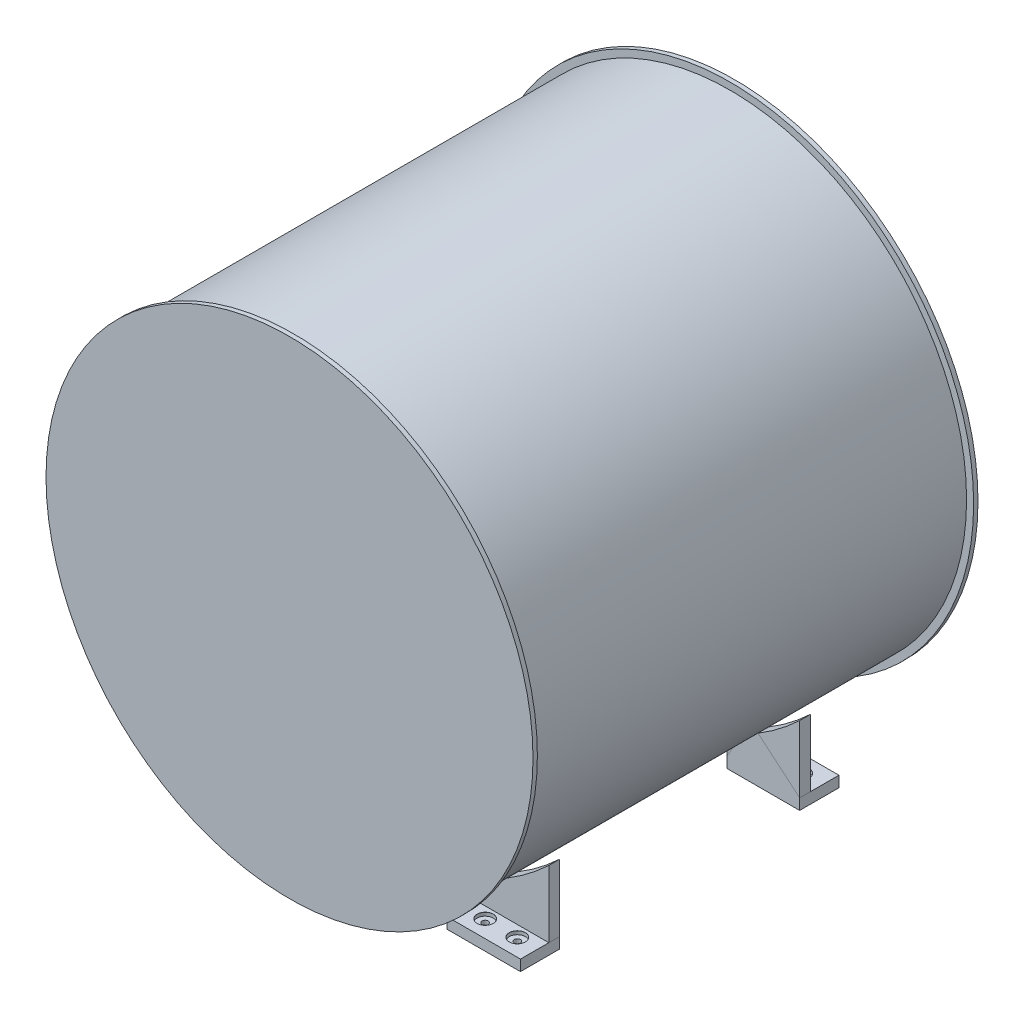
from build123d import *

# Parameters (mm, degrees)
SKETCH1_R                                   = 101.520631511
BOSS_EXTRUDE1_DEPTH                         = 254
SKETCH3_R                                   = 137.670707206
BOSS_EXTRUDE2_DEPTH                         = 254
SKETCH7_R                                   = 141.773218919
BOSS_EXTRUDE3_DEPTH                         = 2.54
SKETCH8_R                                   = 141.773218919
BOSS_EXTRUDE4_DEPTH                         = 2.54
BOSS_EXTRUDE5_DEPTH                         = 6.35
BOSS_EXTRUDE6_DEPTH                         = 6.35
CBORE_FOR_M3_HEX_HEAD_CAP_SCREW1_AT_2_COUNT = 2
CBORE_FOR_M3_HEX_HEAD_CAP_SCREW1_AT_2_PITCH = 18.694620376


with BuildPart() as part:
    # Sketch1 → Boss-Extrude1 (new body)
    with BuildSketch(Plane.XY):
        Circle(SKETCH1_R)
    extrude(amount=BOSS_EXTRUDE1_DEPTH)

    # Sketch3 → Boss-Extrude2 (add)
    with BuildSketch(Plane.XY):
        Circle(SKETCH3_R)
    extrude(amount=BOSS_EXTRUDE2_DEPTH)

    # Sketch7 → Boss-Extrude3 (add)
    with BuildSketch(Plane.XY):
        Circle(SKETCH7_R)
    extrude(amount=-BOSS_EXTRUDE3_DEPTH)

    # Sketch8 → Boss-Extrude4 (add)
    with BuildSketch(Plane.XY.offset(254)):
        Circle(SKETCH8_R)
    extrude(amount=BOSS_EXTRUDE4_DEPTH)


with BuildPart() as body_2:
    # Sketch9 → Boss-Extrude5 (new body)
    with BuildSketch(Plane.XY.offset(50.8)):
        with BuildLine():
            Line((97.638005055, -102.793314818), (97.638005055, -141.773218919))
            Line((97.638005055, -141.773218919), (55.292539207, -141.773218919))
            Line((55.292539207, -141.773218919), (55.292539207, -130.546469545))
            ThreePointArc((55.292539207, -130.546469545), (77.714202315, -118.575496461), (97.638005055, -102.793314818))
        make_face()
    extrude(amount=BOSS_EXTRUDE5_DEPTH)


with BuildPart() as body_3:
    # Mirror2: mirrored copy
    add(body_2.part.mirror(Plane(origin=(0, 0, 0), x_dir=(0, 0, 1), z_dir=(1, 0, 0))))


with BuildPart() as body_4:
    # Mirror3: mirrored copy
    add(body_3.part.mirror(Plane.XY.offset(127)))

    # Sketch11 → Boss-Extrude6 (add)
    with BuildSketch(Plane.XZ.offset(141.773218919)):
        Polygon((-97.638005055, 203.2), (-97.638005055, 219.705564762), (-54.877576599, 219.705564762), (-55.292539207, 203.2), (-55.292539207, 196.85), (-97.638005055, 196.85), align=None)
    extrude(amount=BOSS_EXTRUDE6_DEPTH)


with BuildPart() as body_5:
    # Mirror3 2: mirrored copy
    add(body_2.part.mirror(Plane.XY.offset(127)))


with BuildPart() as body_6:
    # Mirror4: mirrored copy
    add(body_4.part.mirror(Plane.XY.offset(127)))


with BuildPart() as body_7:
    # Mirror5: mirrored copy
    add(body_4.part.mirror(Plane(origin=(0, 0, 0), x_dir=(0, 0, 1), z_dir=(1, 0, 0))))

    # Mirror8 copy 2 sketch → Mirror8 copy 2 (revolve, cut)
    with BuildSketch(Plane(origin=(85.749939421, -141.773218919, 209.651903767), x_dir=(0, 0, -1), z_dir=(-1, 0, 0))):
        Polygon((0, 0), (0, 6.351), (1.8, 6.351), (1.8, 2), (4.6755, 2), (4.6755, 0.025), (4.7005, 0), align=None)
    revolve(axis=Axis((85.749939421, -135.423218919, 209.651903767), (0, -1, 0)), mode=Mode.SUBTRACT)

    # Mirror8 copy 3 sketch → Mirror8 copy 3 (revolve, cut)
    with BuildSketch(Plane(origin=(67.055319044, -141.773218919, 209.651903767), x_dir=(0, 0, -1), z_dir=(-1, 0, 0))):
        Polygon((0, 0), (0, 6.351), (1.8, 6.351), (1.8, 2), (4.6755, 2), (4.6755, 0.025), (4.7005, 0), align=None)
    revolve(axis=Axis((67.055319044, -135.423218919, 209.651903767), (0, -1, 0)), mode=Mode.SUBTRACT)


with BuildPart() as body_8:
    # Mirror5 2: mirrored copy
    add(body_6.part.mirror(Plane(origin=(0, 0, 0), x_dir=(0, 0, 1), z_dir=(1, 0, 0))))


with BuildPart() as body_6_1:
    add(body_6.part)

    # Sketch13 → CBORE for M3 Hex Head Cap Screw1 (revolve, cut)
    with BuildSketch(Plane(origin=(-85.749939421, -141.773218919, 44.348096233), x_dir=(0, 0, 1), z_dir=(1, 0, 0))):
        Polygon((0, 0), (0, 6.351), (1.8, 6.351), (1.8, 2), (4.6755, 2), (4.6755, 0.025), (4.7005, 0), align=None)
    cbore_for_m3_hex_head_cap_screw1 = revolve(axis=Axis((-85.749939421, -135.423218919, 44.348096233), (0, -1, 0)), mode=Mode.SUBTRACT)

    # CBORE for M3 Hex Head Cap Screw1 at 2: CBORE for M3 Hex Head Cap Screw1 ×2
    with Locations(*[(i * CBORE_FOR_M3_HEX_HEAD_CAP_SCREW1_AT_2_PITCH, 0, 0) for i in range(1, CBORE_FOR_M3_HEX_HEAD_CAP_SCREW1_AT_2_COUNT)]):
        add(cbore_for_m3_hex_head_cap_screw1, mode=Mode.SUBTRACT)


with BuildPart() as body_4_1:
    add(body_4.part)

    # Mirror7: CBORE for M3 Hex Head Cap Screw1 across plane
    add(cbore_for_m3_hex_head_cap_screw1.mirror(Plane.XY.offset(127)), mode=Mode.SUBTRACT)

    # Mirror7 copy 1 sketch → Mirror7 copy 1 (revolve, cut)
    with BuildSketch(Plane(origin=(-67.055319044, -141.773218919, 209.651903767), x_dir=(0, 0, -1), z_dir=(1, 0, 0))):
        Polygon((0, 0), (0, -6.351), (1.8, -6.351), (1.8, -2), (4.6755, -2), (4.6755, -0.025), (4.7005, 0), align=None)
    revolve(axis=Axis((-67.055319044, -135.423218919, 209.651903767), (0, 1, 0)), mode=Mode.SUBTRACT)


with BuildPart() as body_8_1:
    add(body_8.part)

    # Mirror8: CBORE for M3 Hex Head Cap Screw1 across plane
    add(cbore_for_m3_hex_head_cap_screw1.mirror(Plane(origin=(0, 0, 0), x_dir=(0, 0, 1), z_dir=(1, 0, 0))), mode=Mode.SUBTRACT)

    # Mirror8 copy 1 sketch → Mirror8 copy 1 (revolve, cut)
    with BuildSketch(Plane(origin=(67.055319044, -141.773218919, 44.348096233), x_dir=(0, 0, 1), z_dir=(-1, 0, 0))):
        Polygon((0, 0), (0, -6.351), (1.8, -6.351), (1.8, -2), (4.6755, -2), (4.6755, -0.025), (4.7005, 0), align=None)
    revolve(axis=Axis((67.055319044, -135.423218919, 44.348096233), (0, 1, 0)), mode=Mode.SUBTRACT)


solid = Compound([part.part, body_2.part, body_3.part, body_5.part, body_7.part, body_6_1.part, body_4_1.part, body_8_1.part])
